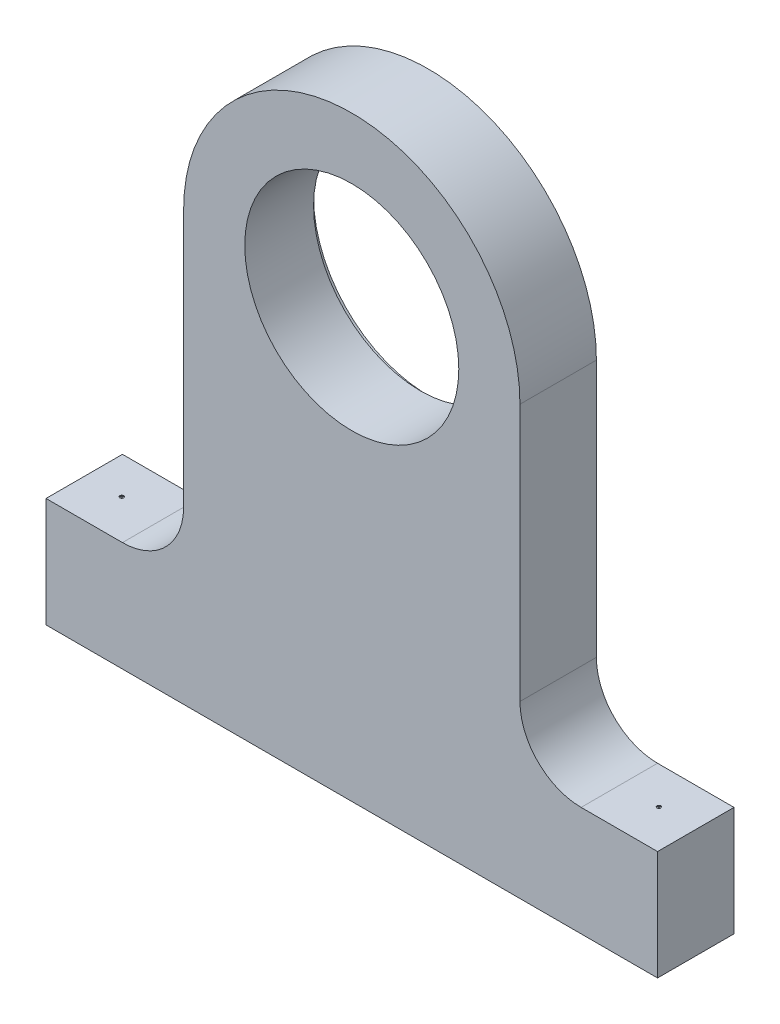
from build123d import *

# Parameters (mm, degrees)
SKETCH1_R                                           = 87.5
BOSS_EXTRUDE1_DEPTH                                 = 62.5
FILLET1_R                                           = 50
SKETCH2_R                                           = 93.75
CUT_EXTRUDE3_DEPTH                                  = 6.25
CBORE_FOR_00_BINDING_HEAD_MACHINE_SCREW_D           = 1.397
CBORE_FOR_00_BINDING_HEAD_MACHINE_SCREW_CBORE_D     = 3.175
CBORE_FOR_00_BINDING_HEAD_MACHINE_SCREW_CBORE_DEPTH = 0.7112


with BuildPart() as part:
    # Sketch1 → Boss-Extrude1 (new body)
    with BuildSketch(Plane.XY):
        with BuildLine():
            Line((-228.544776119, -223.134328358), (271.455223881, -223.134328358))
            Line((271.455223881, -223.134328358), (271.455223881, -133.582089552))
            Line((271.455223881, -133.582089552), (158.955223881, -133.582089552))
            Line((158.955223881, -133.582089552), (158.955223881, 126.865671642))
            ThreePointArc((158.955223881, 126.865671642), (21.455223881, 264.365671642), (-116.044776119, 126.865671642))
            Line((-116.044776119, 126.865671642), (-116.044776119, -133.582089552))
            Line((-116.044776119, -133.582089552), (-228.544776119, -133.582089552))
            Line((-228.544776119, -133.582089552), (-228.544776119, -223.134328358))
        make_face()
        with Locations((21.455223881, 126.865671642)):
            Circle(SKETCH1_R, mode=Mode.SUBTRACT)
    extrude(amount=BOSS_EXTRUDE1_DEPTH)

    # Fillet1
    fillet1_edges = [part.edges().sort_by_distance(p)[0] for p in [
        (-116.044776119, -133.582089552, 31.25),
        (158.955223881, -133.582089552, 31.25),
    ]]
    fillet(fillet1_edges, radius=FILLET1_R)

    # Sketch2 → Cut-Extrude3 (cut)
    with BuildSketch(Plane.XY):
        with Locations((21.455223881, 126.865671642)):
            Circle(SKETCH2_R)
    extrude(amount=CUT_EXTRUDE3_DEPTH, mode=Mode.SUBTRACT)

    # CBORE for #00 Binding Head Machine Screw1 (through all)
    with Locations(Plane(origin=(0, -133.582089552, 0), x_dir=(1, 0, 0), z_dir=(0, 1, 0))):
        with Locations((-198.798502654, -30.325345844), (240.412221484, -30.325345844)):
            CounterBoreHole(CBORE_FOR_00_BINDING_HEAD_MACHINE_SCREW_D / 2, CBORE_FOR_00_BINDING_HEAD_MACHINE_SCREW_CBORE_D / 2, CBORE_FOR_00_BINDING_HEAD_MACHINE_SCREW_CBORE_DEPTH)


solid = part.part
